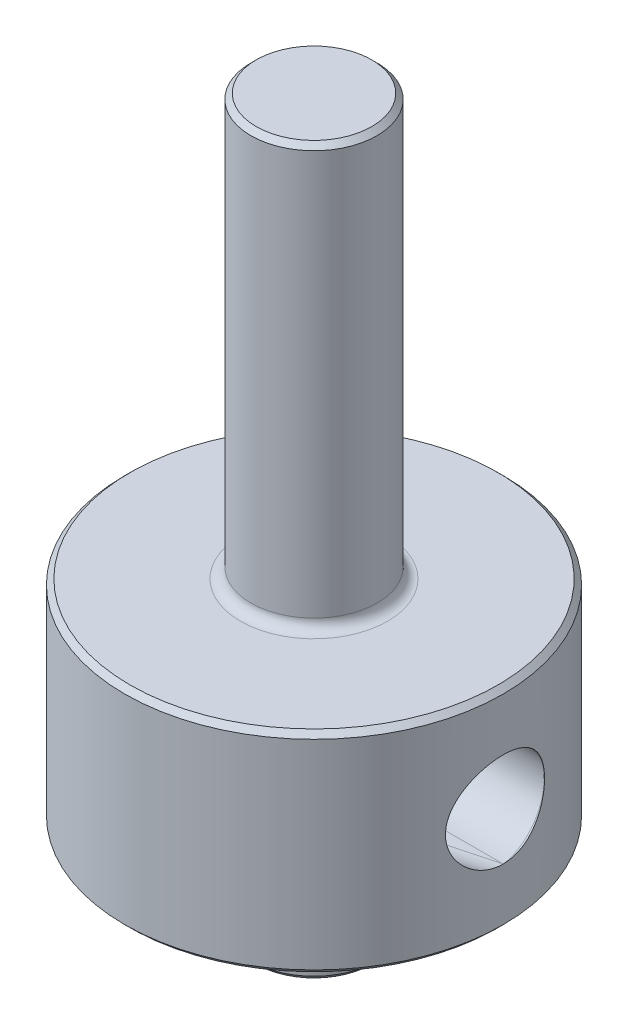
from build123d import *

# Parameters (mm, degrees)
ESBO_O2_R                  = 2.25
CORTE_EXTRUS_O2_DEPTH      = 19
ESBO_O7_R                  = 2.25
CORTE_EXTRUS_O6_DEPTH      = 3.329371528
CORTE_EXTRUS_O6_DEPTH_BACK = 20.716036402
CUT_EXTRUDE1_DEPTH         = 2.25
FILLET1_R                  = 0.5
CHAMFER1_SIZE              = 0.25
CHAMFER4_SIZE              = 0.25


with BuildPart() as part:
    # Esboço1 → Revolução1 (revolve)
    with BuildSketch(Plane.XY):
        Polygon((0, 25), (3, 25), (3, 5), (9, 5), (9, -5), (3, -5), (3, -9.5), (0, -9.5), (0, 0), align=None)
    revolve(axis=Axis((0, 0, 0), (0, 1, 0)))

    # Esboço2 → Corte-extrusão2 (cut, through all)
    with BuildSketch(Plane.ZY.offset(9)):
        Circle(ESBO_O2_R)
    extrude(amount=-CORTE_EXTRUS_O2_DEPTH, mode=Mode.SUBTRACT)

    # Esboço7 → Corte-extrusão6 (cut, two sides)
    with BuildSketch(Plane(origin=(-7.794228634, 0, 4.5), x_dir=(0.258819045, 0, 0.965925826), z_dir=(-0.965925826, 0, 0.258819045))) as corte_extrus_o6_sk:
        Circle(ESBO_O7_R)
    extrude(amount=CORTE_EXTRUS_O6_DEPTH, mode=Mode.SUBTRACT)
    extrude(corte_extrus_o6_sk.sketch, amount=-CORTE_EXTRUS_O6_DEPTH_BACK, mode=Mode.SUBTRACT)

    # Sketch1 → Cut-Extrude1 (cut, symmetric)
    with BuildSketch(Plane(origin=(0, 0, 0), x_dir=(1, 0, 0), z_dir=(0, 1, 0))):
        Polygon((9, 0), (-10.844388007, 0), (-10.42876147, -5.205920946), align=None)
    extrude(amount=CUT_EXTRUDE1_DEPTH, both=True, mode=Mode.SUBTRACT)

    # Fillet1
    fillet1_edges = [part.edges().sort_by_distance(p)[0] for p in [
        (-3, -5, 0),
        (-3, 5, 0),
    ]]
    fillet(fillet1_edges, radius=FILLET1_R)

    # Chamfer1
    chamfer1_edges = [part.edges().sort_by_distance(p)[0] for p in [
        (-3, -9.5, 0),
        (-3, 25, 0),
    ]]
    chamfer(chamfer1_edges, length=CHAMFER1_SIZE)

    # Chamfer4
    chamfer4_edges = [part.edges().sort_by_distance(p)[0] for p in [
        (-9, -5, 0),
        (-9, 5, 0),
    ]]
    chamfer(chamfer4_edges, length=CHAMFER4_SIZE)


solid = part.part
